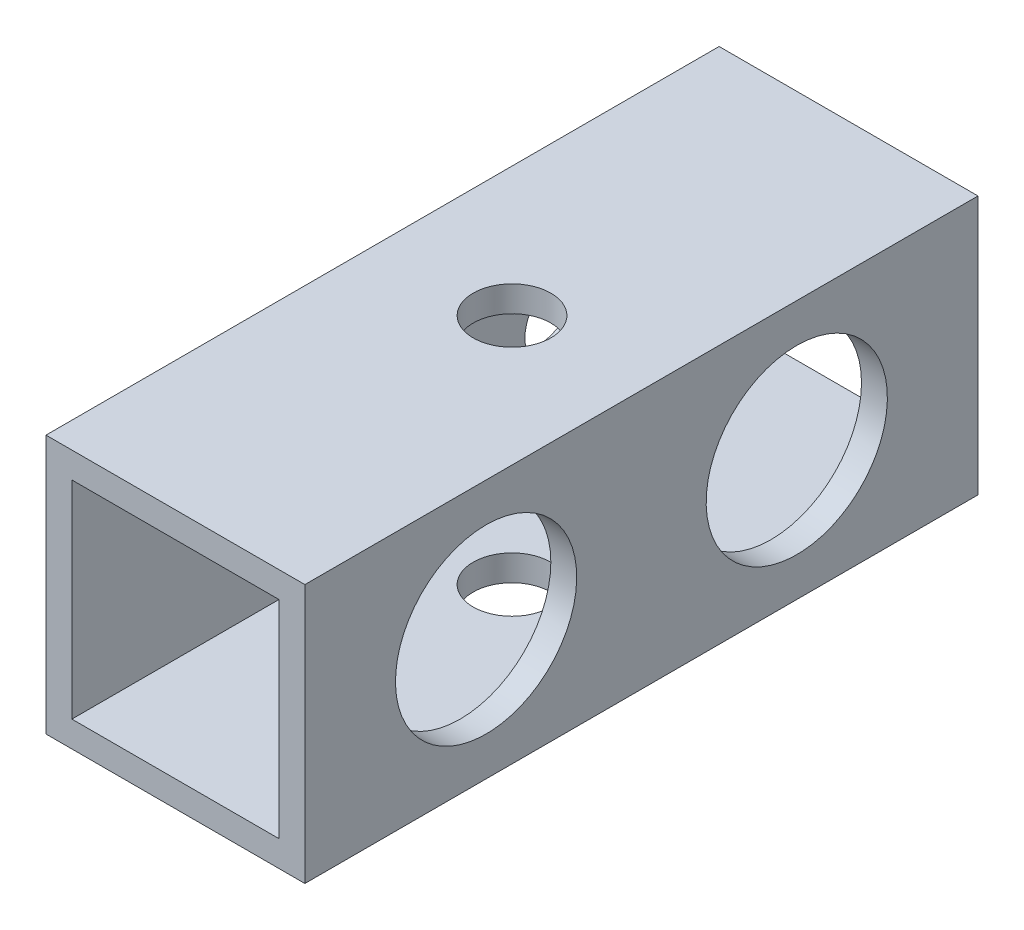
from build123d import *

# Parameters (mm, degrees)
SKETCH_1_W          = 10
SKETCH_1_H          = 10
SKETCH_1_W_2        = 8
SKETCH_1_H_2        = 8
EXTRUDE_1_DEPTH     = 26
SKETCH_2_R          = 1.5
CUT_EXTRUDE_1_DEPTH = 10
SKETCH_3_R          = 1.5
CUT_EXTRUDE_2_DEPTH = 10
SKETCH_4_R          = 3.5
CUT_EXTRUDE_3_DEPTH = 5


with BuildPart() as part:
    # 草图1 → 拉伸-薄壁1 (new body)
    with BuildSketch(Plane.XY):
        Rectangle(SKETCH_1_W, SKETCH_1_H)
        Rectangle(SKETCH_1_W_2, SKETCH_1_H_2, mode=Mode.SUBTRACT)
    extrude(amount=EXTRUDE_1_DEPTH)

    # 草图2 → 切除-拉伸1 (cut)
    with BuildSketch(Plane.ZY.offset(5)):
        with Locations((7, 0)):
            Circle(SKETCH_2_R)
        with Locations((19, 0)):
            Circle(SKETCH_2_R)
    extrude(amount=-CUT_EXTRUDE_1_DEPTH, mode=Mode.SUBTRACT)

    # 草图3 → 切除-拉伸2 (cut)
    with BuildSketch(Plane.XZ.offset(5)):
        with Locations((0, 13)):
            Circle(SKETCH_3_R)
    extrude(amount=-CUT_EXTRUDE_2_DEPTH, mode=Mode.SUBTRACT)

    # 草图4 → 切除-拉伸3 (cut)
    with BuildSketch(Plane(origin=(5, 0, 0), x_dir=(0, 0, -1), z_dir=(1, 0, 0))):
        with Locations((-19, 0)):
            Circle(SKETCH_4_R)
        with Locations((-7, 0)):
            Circle(SKETCH_4_R)
    extrude(amount=-CUT_EXTRUDE_3_DEPTH, mode=Mode.SUBTRACT)


solid = part.part
